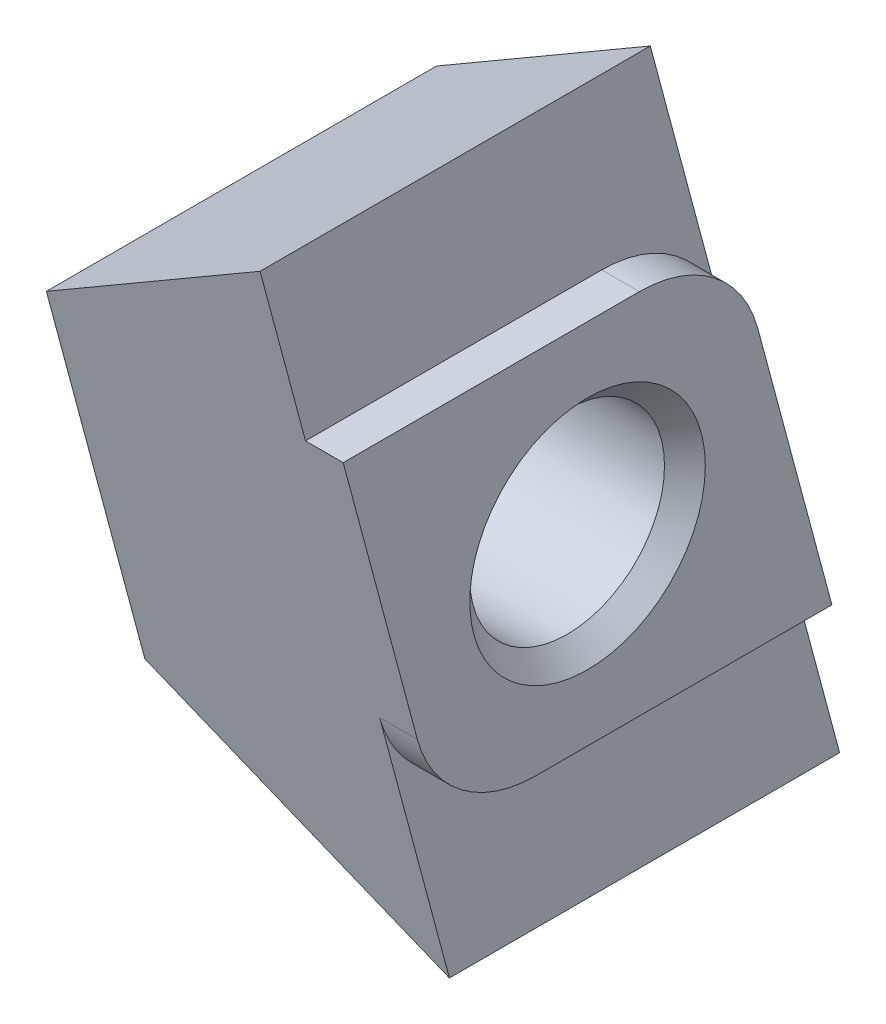
from build123d import *

# Parameters (mm, degrees)
EXTRUDE1_DEPTH = 0.8
EXTRUDE2_DEPTH = 5.5
DRAFT1_ANGLE   = -33.206570315
DRAFT2_ANGLE   = -33.206570315
HOLEWZD1_D     = 4.134
HOLEWZD1_DEPTH = 6.300025
CHAMFER1_SIZE  = 0.433


with BuildPart() as part:
    # Sketch1 → Extrude1 (new body)
    with BuildSketch(Plane(origin=(0, 0, 0), x_dir=(0, 0, -1), z_dir=(1, 0, 0))):
        with BuildLine():
            Line((1.101052702, 3.9), (-5.186106572, 3.9))
            Line((-5.186106572, 3.9), (-3.612459851, -1.972929517))
            ThreePointArc((-3.612459851, -1.972929517), (-2.683832418, -3.362718685), (-1.101052702, -3.9))
            Line((-1.101052702, -3.9), (5.186106572, -3.9))
            Line((5.186106572, -3.9), (3.612459851, 1.972929517))
            ThreePointArc((3.612459851, 1.972929517), (2.683832418, 3.362718685), (1.101052702, 3.9))
        make_face()
    extrude(amount=-EXTRUDE1_DEPTH)

    # Sketch2 → Extrude2 (add)
    with BuildSketch(Plane.ZY.offset(0.8)):
        with BuildLine():
            Line((2.131485778, -7.5), (-6.150723665, -7.5))
            add(Edge.make_bspline(
                [(-2.131485778, 7.5), (-3.471231741, 2.5), (-4.810977703, -2.5), (-6.150723665, -7.5)],
                knots=[0, 0, 0, 0, 1, 1, 1, 1], degree=3))
            Line((-2.131485778, 7.5), (6.150723665, 7.5))
            add(Edge.make_bspline(
                [(2.131485778, -7.5), (3.471231741, -2.5), (4.810977703, 2.5), (6.150723665, 7.5)],
                knots=[0, 0, 0, 0, 1, 1, 1, 1], degree=3))
        make_face()
    extrude(amount=EXTRUDE2_DEPTH)

    # Draft1
    draft1_faces = [part.faces().sort_by_distance(p)[0] for p in [
        (-3.55, 7.5, 2.009618943),
    ]]
    draft(draft1_faces, Plane(origin=(-0.8, 0, 4.141104722), x_dir=(0, 0, 1), z_dir=(1, 0, 0)), DRAFT1_ANGLE)

    # Draft2
    draft2_faces = [part.faces().sort_by_distance(p)[0] for p in [
        (-3.55, -7.5, -2.009618943),
    ]]
    draft(draft2_faces, Plane(origin=(-0.8, 0, 4.141104722), x_dir=(0, 0, 1), z_dir=(1, 0, 0)), DRAFT2_ANGLE)

    # HoleWzd1
    with Locations(Plane.ZY.offset(6.3)):
        with Locations((0, 0)):
            Hole(HOLEWZD1_D / 2, depth=HOLEWZD1_DEPTH)

    # Chamfer1
    chamfer1_edges = [part.edges().sort_by_distance(p)[0] for p in [
        (0, 0, 2.067),
        (-6.3, 0, 2.067),
    ]]
    chamfer(chamfer1_edges, length=CHAMFER1_SIZE)


solid = part.part
